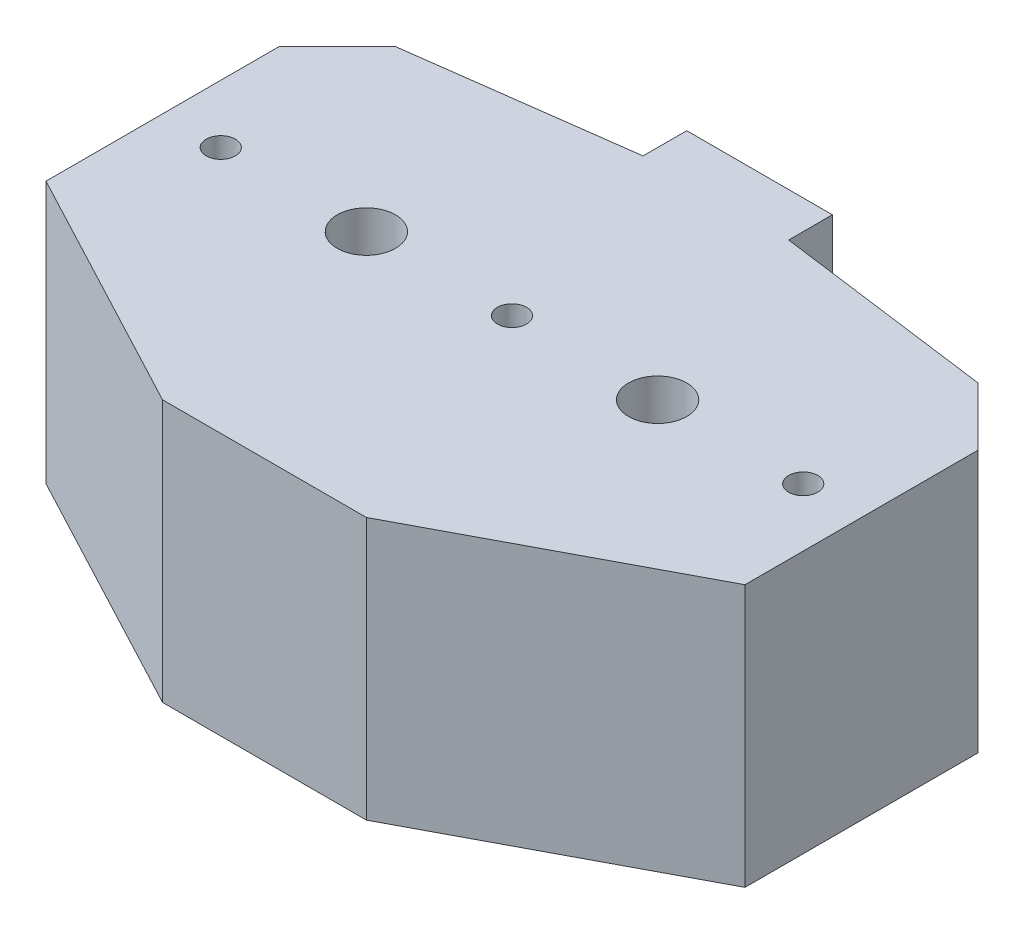
from build123d import *

# Parameters (mm, degrees)
SKETCH_1_R      = 1
SKETCH_1_R_2    = 2
EXTRUDE_1_DEPTH = 18


with BuildPart() as part:
    # Эскиз1 → Бобышка-Вытянуть1 (new body)
    with BuildSketch(Plane(origin=(0, 0, 0), x_dir=(1, 0, 0), z_dir=(0, 1, 0))):
        Polygon((24, 8), (24, -8), (7, -17), (-7, -17), (-24, -8), (-24, 8), (-20, 12), (-5, 14), (-5, 17), (5, 17), (5, 14), (20, 12), align=None)
        Circle(SKETCH_1_R, mode=Mode.SUBTRACT)
        with Locations((20, 0)):
            Circle(SKETCH_1_R, mode=Mode.SUBTRACT)
        with Locations((-20, 0)):
            Circle(SKETCH_1_R, mode=Mode.SUBTRACT)
        with Locations((-10, 0)):
            Circle(SKETCH_1_R_2, mode=Mode.SUBTRACT)
        with Locations((10, 0)):
            Circle(SKETCH_1_R_2, mode=Mode.SUBTRACT)
    extrude(amount=EXTRUDE_1_DEPTH)


solid = part.part
